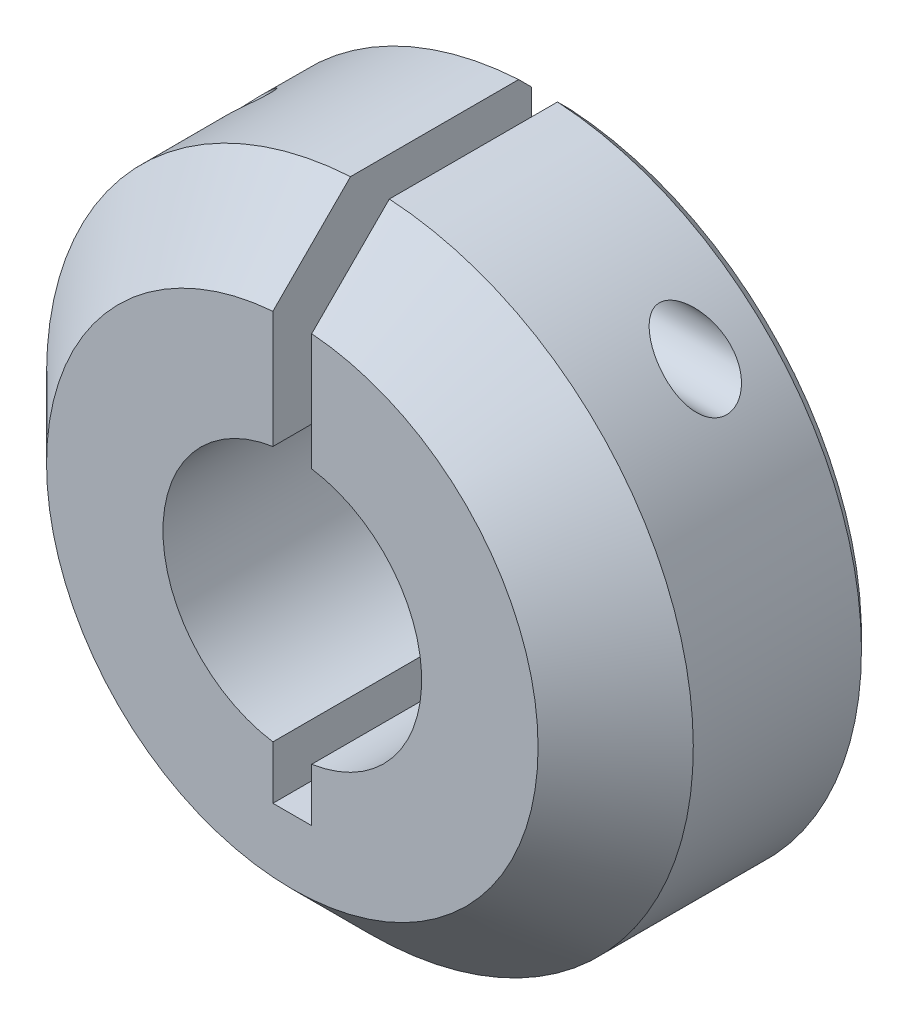
from build123d import *

# Parameters (mm, degrees)
BOSS_EXTRUDE1_DEPTH = 10
CHAMFER1_SIZE       = 3
CHAMFER2_SIZE       = 0.5
SKETCH22_R          = 1.225
CUT_EXTRUDE1_DEPTH  = 10
SKETCH23_R          = 0.725
CUT_EXTRUDE2_DEPTH  = 27.7500001


with BuildPart() as part:
    # Sketch1 → Boss-Extrude1 (new body)
    with BuildSketch(Plane.XY):
        with BuildLine():
            Line((-0.75, 4.943429983), (-0.75, 12.477479713))
            ThreePointArc((-0.75, 12.477479713), (0, -12.5), (0.75, 12.477479713))
            Line((0.75, 12.477479713), (0.75, 4.943429983))
            ThreePointArc((0.75, 4.943429983), (5, 0), (0.75, -4.943429983))
            Line((0.75, -4.943429983), (0.75, -7))
            Line((0.75, -7), (-0.75, -7))
            Line((-0.75, -7), (-0.75, -4.943429983))
            ThreePointArc((-0.75, -4.943429983), (-5, 0), (-0.75, 4.943429983))
        make_face()
    extrude(amount=BOSS_EXTRUDE1_DEPTH)

    # Chamfer1
    chamfer1_edges = [part.edges().sort_by_distance(p)[0] for p in [
        (0, -12.5, 10),
    ]]
    chamfer(chamfer1_edges, length=CHAMFER1_SIZE)

    # Chamfer2
    chamfer2_edges = [part.edges().sort_by_distance(p)[0] for p in [
        (0, -12.5, 0),
    ]]
    chamfer(chamfer2_edges, length=CHAMFER2_SIZE)

    # Sketch22 → Cut-Extrude1 (cut)
    with BuildSketch(Plane(origin=(14.25, 0, 0), x_dir=(0, 0, -1), z_dir=(1, 0, 0))):
        with Locations((-3, 9)):
            Circle(SKETCH22_R)
    extrude(amount=-CUT_EXTRUDE1_DEPTH, mode=Mode.SUBTRACT)

    # Sketch23 → Cut-Extrude2 (cut, through all)
    with BuildSketch(Plane(origin=(14.25, 0, 0), x_dir=(0, 0, -1), z_dir=(1, 0, 0))):
        with Locations((-3, 9)):
            Circle(SKETCH23_R)
    extrude(amount=-CUT_EXTRUDE2_DEPTH, mode=Mode.SUBTRACT)


solid = part.part
